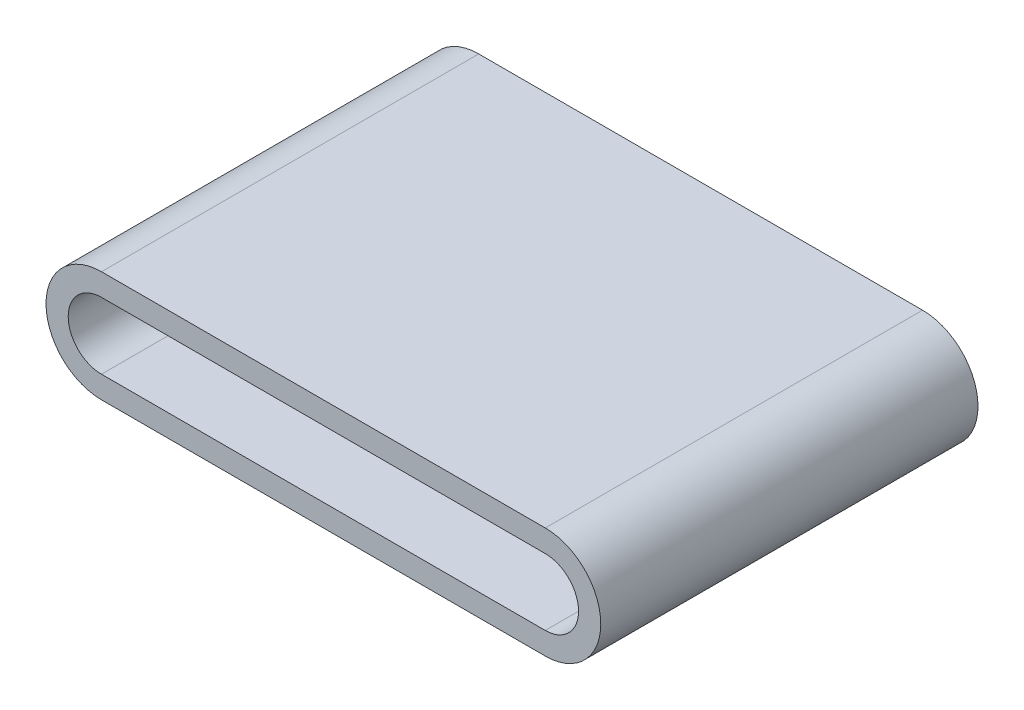
from build123d import *

# Parameters (mm, degrees)
EXTRUDE_2_DEPTH      = 20
EXTRUDE_2_DEPTH_BACK = 10
EXTRUDE_1_DEPTH      = 55


with BuildPart() as part:
    # 草图3 → 凸台-拉伸2 (new body, two sides)
    with BuildSketch(Plane.XY) as extrude_2_sk:
        with BuildLine():
            Line((0, 12.5), (100, 12.5))
            ThreePointArc((100, 12.5), (112.5, 0), (100, -12.5))
            Line((100, -12.5), (0, -12.5))
            ThreePointArc((0, -12.5), (-12.5, 0), (0, 12.5))
        make_face()
    extrude(amount=EXTRUDE_2_DEPTH)
    extrude(extrude_2_sk.sketch, amount=-EXTRUDE_2_DEPTH_BACK)

    # 草图4 → 拉伸-薄壁1 (add)
    with BuildSketch(Plane.XY.offset(20)):
        with BuildLine():
            Line((100, 12.5), (0, 12.5))
            ThreePointArc((0, 12.5), (-12.5, 0), (0, -12.5))
            Line((0, -12.5), (100, -12.5))
            ThreePointArc((100, -12.5), (112.5, 0), (100, 12.5))
        make_face()
        with BuildLine():
            Line((100, 7.5), (0, 7.5))
            ThreePointArc((0, 7.5), (-7.5, 0), (0, -7.5))
            Line((0, -7.5), (100, -7.5))
            ThreePointArc((100, -7.5), (107.5, 0), (100, 7.5))
        make_face(mode=Mode.SUBTRACT)
    extrude(amount=EXTRUDE_1_DEPTH)


solid = part.part
